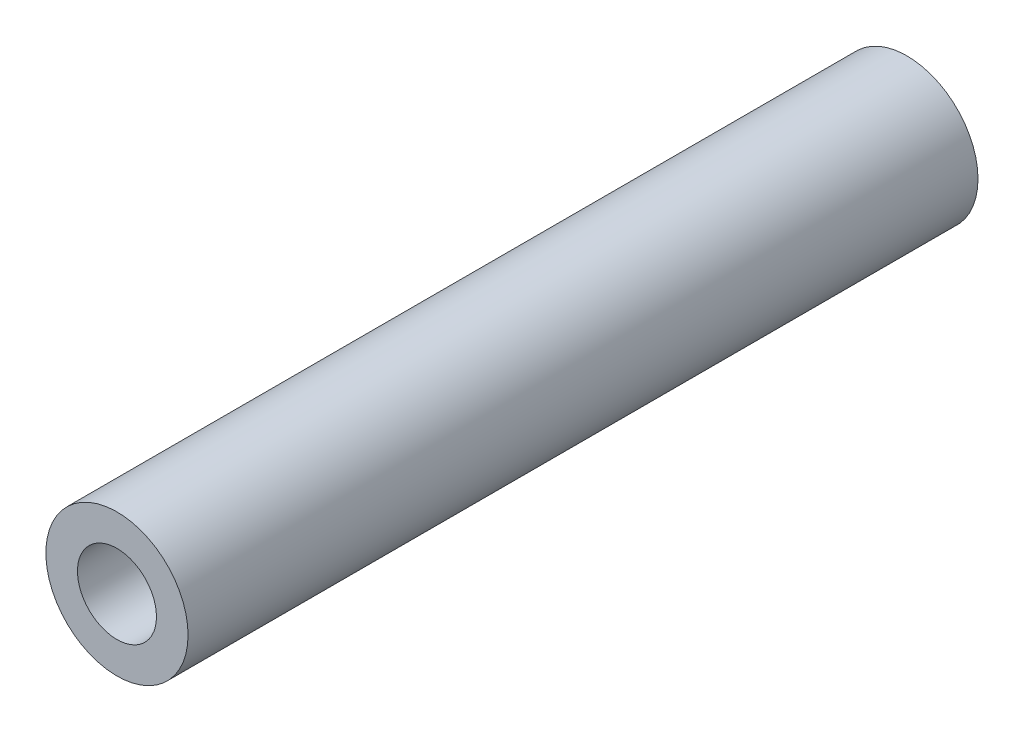
from build123d import *

# Parameters (mm, degrees)
SKETCH1_R           = 2.8575
SKETCH1_R_2         = 1.5875
BOSS_EXTRUDE1_DEPTH = 31.75


with BuildPart() as part:
    # Sketch1 → Boss-Extrude1 (new body)
    with BuildSketch(Plane.XY):
        Circle(SKETCH1_R)
        Circle(SKETCH1_R_2, mode=Mode.SUBTRACT)
    extrude(amount=BOSS_EXTRUDE1_DEPTH)


solid = part.part
